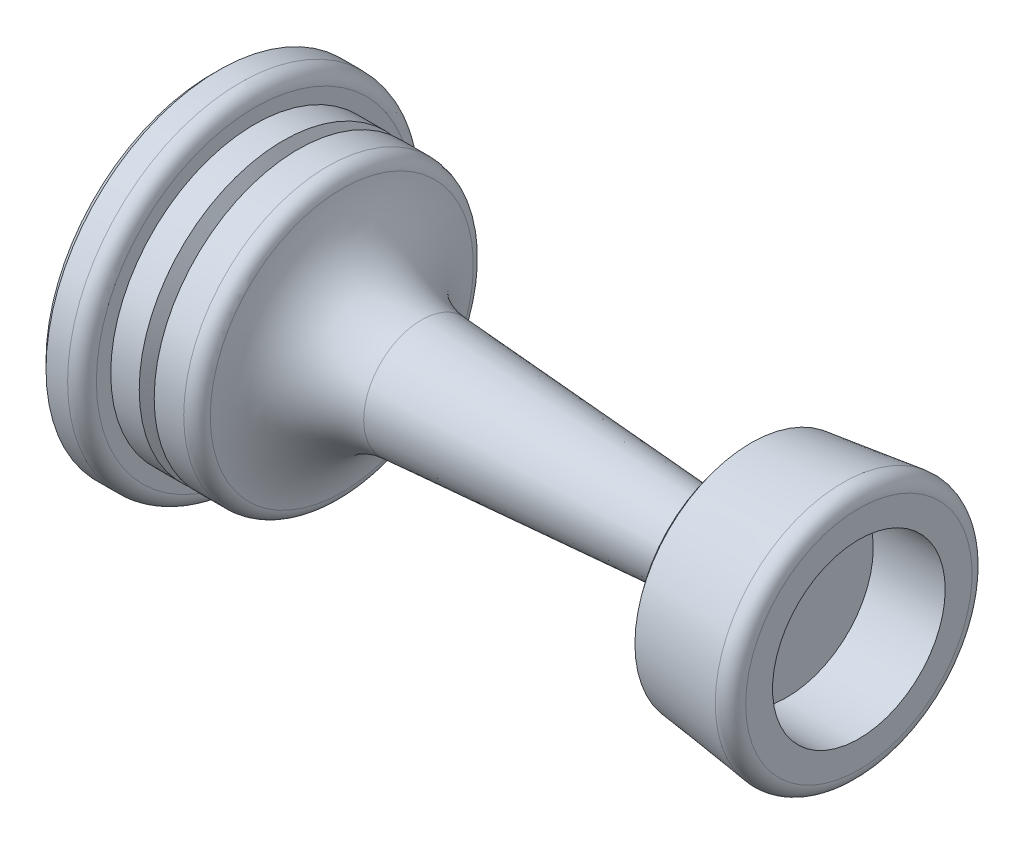
from build123d import *

# Parameters (mm, degrees)
SKETCH3_R          = 6
CUT_EXTRUDE1_DEPTH = 5
SKETCH4_R          = 6
CUT_EXTRUDE2_DEPTH = 5
FILLET1_R          = 1
CHAMFER1_SIZE      = 0.5
CHAMFER1_SIZE2     = 0.575875553


with BuildPart() as part:
    # Sketch1 → Revolve1 (revolve)
    with BuildSketch(Plane.XY, mode=Mode.PRIVATE) as revolve1_sk:
        with BuildLine():
            Line((0, 0), (0, 11.5))
            Line((0, 11.5), (0.5, 12))
            Line((0.5, 12), (2, 12))
            ThreePointArc((2, 12), (2.707106781, 11.707106781), (3, 11))
            Line((3, 11), (3, 10))
            Line((3, 10), (8.07179677, 10))
            ThreePointArc((8.07179677, 10), (8.72645044, 9.755928946), (9.061540088, 9.142857143))
            ThreePointArc((9.061540088, 9.142857143), (10.921361567, 5.599464972), (14.595561276, 4.013646409))
            Line((14.595561276, 4.013646409), (37, 2.5))
            Line((37, 2.5), (37, 8))
            Line((37, 8), (45, 9))
            Line((45, 9), (45, 0))
            Line((45, 0), (0, 0))
        make_face()
    revolve(revolve1_sk.sketch.rotate(Axis((0, 0, 0), (1, 0, 0)), 90), axis=Axis((0, 0, 0), (1, 0, 0)))  # turned: the seam where the file's is

    # Sketch2 → Cut-Revolve1 (revolve, cut)
    with BuildSketch(Plane.XY, mode=Mode.PRIVATE) as cut_revolve1_sk:
        Polygon((4.979432949, 10), (5.5, 9), (6.020567051, 10), align=None)
    revolve(cut_revolve1_sk.sketch.rotate(Axis((0, 0, 0), (1, 0, 0)), 90), axis=Axis((0, 0, 0), (1, 0, 0)), mode=Mode.SUBTRACT)  # turned: the seam where the file's is

    # Sketch3 → Cut-Extrude1 (cut)
    with BuildSketch(Plane.ZY):
        with Locations(Location((0, 0, 0), (0, 0, 270))):  # turned: the seam where the file's is
            Circle(SKETCH3_R)
    extrude(amount=-CUT_EXTRUDE1_DEPTH, mode=Mode.SUBTRACT)

    # Sketch4 → Cut-Extrude2 (cut)
    with BuildSketch(Plane(origin=(45, 0, 0), x_dir=(0, 0, -1), z_dir=(1, 0, 0))):
        with Locations(Location((0, 0, 0), (0, 0, 270))):  # turned: the seam where the file's is
            Circle(SKETCH4_R)
    extrude(amount=-CUT_EXTRUDE2_DEPTH, mode=Mode.SUBTRACT)

    # Fillet1
    fillet1_edges = [part.edges().sort_by_distance(p)[0] for p in [
        (45, 0, -9),
    ]]
    fillet(fillet1_edges, radius=FILLET1_R)

    # Chamfer1
    chamfer1_edges = [part.edges().sort_by_distance(p)[0] for p in [
        (37, 0, -8),
    ]]
    chamfer1_side = [part.faces().sort_by_distance(p)[0] for p in [
        (40.437982633, 0, -8.429747829),
    ]]
    chamfer(chamfer1_edges, length=CHAMFER1_SIZE, length2=CHAMFER1_SIZE2, reference=chamfer1_side[0])


solid = part.part
